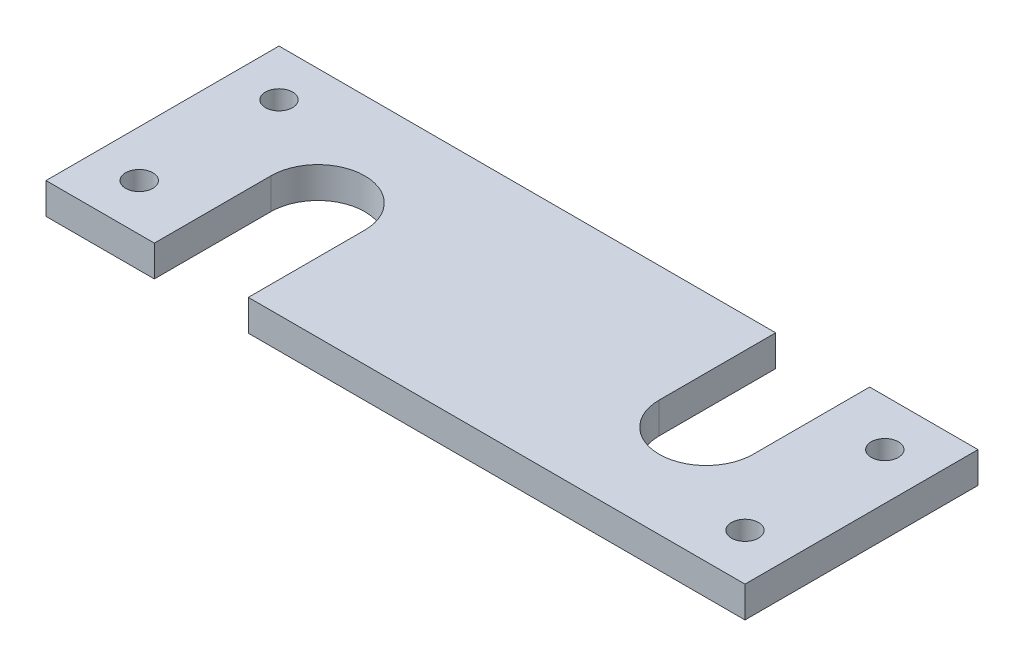
from build123d import *

# Parameters (mm, degrees)
SKETCH2_W           = 90
SKETCH2_H           = 30
BOSS_EXTRUDE1_DEPTH = 4
SKETCH3_R           = 1.75
CUT_EXTRUDE1_DEPTH  = 5


with BuildPart() as part:
    # Sketch2 → Boss-Extrude1 (new body)
    with BuildSketch(Plane(origin=(0, 0, 0), x_dir=(1, 0, 0), z_dir=(0, 1, 0))):
        with Locations((45, 15)):
            Rectangle(SKETCH2_W, SKETCH2_H)
    extrude(amount=BOSS_EXTRUDE1_DEPTH)

    # Sketch3 → Cut-Extrude1 (cut, through all)
    with BuildSketch(Plane(origin=(0, 4, 0), x_dir=(1, 0, 0), z_dir=(0, 1, 0))):
        with Locations((6, 6)):
            Circle(SKETCH3_R)
        with Locations((6, 24)):
            Circle(SKETCH3_R)
        with Locations((84, 24)):
            Circle(SKETCH3_R)
        with Locations((84, 6)):
            Circle(SKETCH3_R)
        with BuildLine():
            Line((13.95, 0), (26.05, 0))
            Line((26.05, 0), (26.05, 15))
            ThreePointArc((26.05, 15), (20, 21.05), (13.95, 15))
            Line((13.95, 15), (13.95, 0))
        make_face()
        with BuildLine():
            Line((63.95, 30), (63.95, 15))
            ThreePointArc((63.95, 15), (70, 8.95), (76.05, 15))
            Line((76.05, 15), (76.05, 30))
            Line((76.05, 30), (63.95, 30))
        make_face()
    extrude(amount=-CUT_EXTRUDE1_DEPTH, mode=Mode.SUBTRACT)


solid = part.part
